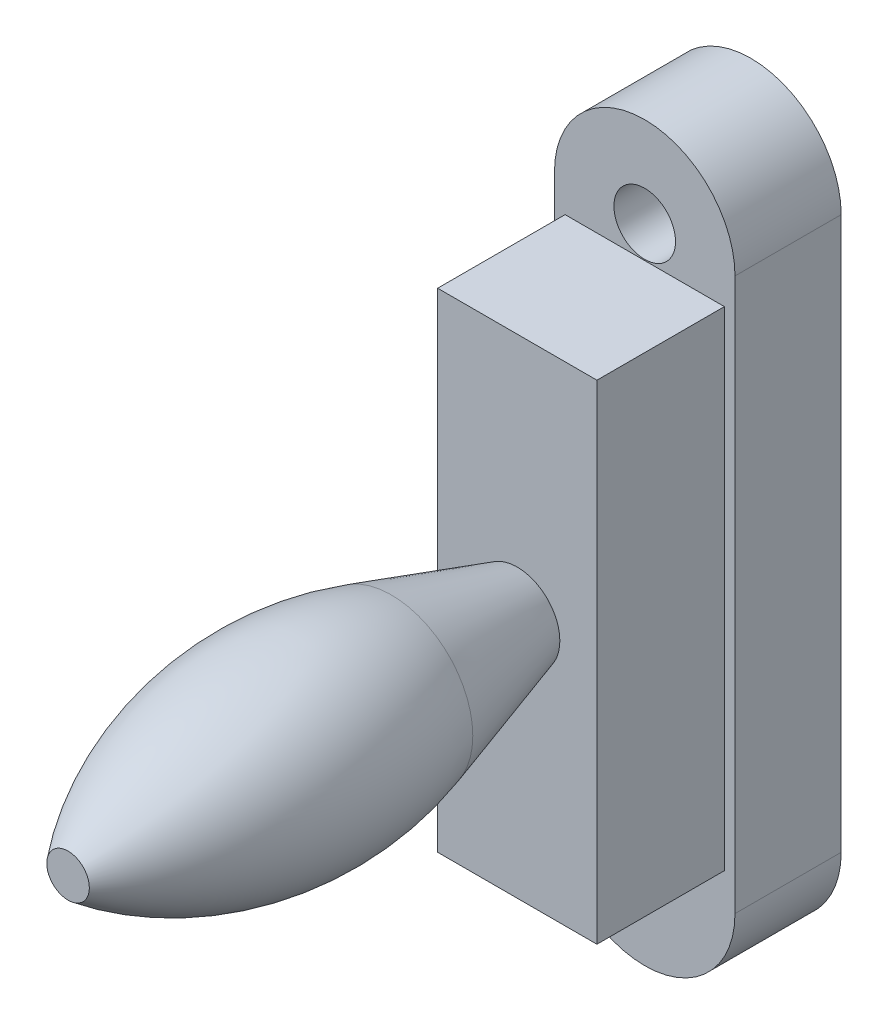
from build123d import *

# Parameters (mm, degrees)
SKETCH1_R           = 1.45
SKETCH1_W           = 4.5
SKETCH1_H           = 20
BOSS_EXTRUDE1_DEPTH = 5
SKETCH2_W           = 7.5
SKETCH2_H           = 23
SKETCH2_W_2         = 4.5
SKETCH2_H_2         = 20
BOSS_EXTRUDE2_DEPTH = 5
SKETCH3_W           = 7.5
SKETCH3_H           = 23
BOSS_EXTRUDE3_DEPTH = 1
CUT_EXTRUDE1_REACH  = 45.372
SKETCH6_R           = 1.25


with BuildPart() as part:
    # Sketch1 → Boss-Extrude1 (new body)
    with BuildSketch(Plane.XY):
        with BuildLine():
            Line((-4.25, 0), (-4.25, 26))
            ThreePointArc((-4.25, 26), (0, 30.25), (4.25, 26))
            Line((4.25, 26), (4.25, 0))
            ThreePointArc((4.25, 0), (0, -4.25), (-4.25, 0))
        make_face()
        with Locations((0, 26)):
            Circle(SKETCH1_R, mode=Mode.SUBTRACT)
        Circle(SKETCH1_R, mode=Mode.SUBTRACT)
        with Locations((0, 13)):
            Rectangle(SKETCH1_W, SKETCH1_H, mode=Mode.SUBTRACT)
    extrude(amount=BOSS_EXTRUDE1_DEPTH)

    # Sketch2 → Boss-Extrude2 (add)
    with BuildSketch(Plane.XY.offset(5)):
        with Locations((0, 13)):
            Rectangle(SKETCH2_W, SKETCH2_H)
        with Locations((0, 13)):
            Rectangle(SKETCH2_W_2, SKETCH2_H_2, mode=Mode.SUBTRACT)
    extrude(amount=BOSS_EXTRUDE2_DEPTH)

    # Sketch3 → Boss-Extrude3 (add)
    with BuildSketch(Plane.XY.offset(10)):
        with Locations((0, 13)):
            Rectangle(SKETCH3_W, SKETCH3_H)
    extrude(amount=BOSS_EXTRUDE3_DEPTH)

    # Sketch5 → Revolve1 (revolve)
    with BuildSketch(Plane(origin=(0, 0, 0), x_dir=(0, 0, -1), z_dir=(1, 0, 0))):
        with BuildLine():
            Line((-11, 13), (-11, 15.003893641))
            Line((-11, 15.003893641), (-16.924450419, 16.829327494))
            ThreePointArc((-16.924450419, 16.829327494), (-24.885658953, 17.288779267), (-32.151240121, 14.001946821))
            Line((-32.151240121, 14.001946821), (-32.151240121, 13))
            Line((-32.151240121, 13), (-11, 13))
        make_face()
    revolve(axis=Axis((0, 13, 32.151240121), (0, 0, -1)))

    # Sketch6 → Cut-Extrude1 (cut, up to next)
    with BuildSketch(Plane.XZ.offset(-1.5), mode=Mode.PRIVATE) as cut_extrude1_sk1:
        with Locations((0, 7.153891294)):
            Circle(SKETCH6_R)
    cut_extrude1_tool1 = extrude(cut_extrude1_sk1.sketch, amount=-CUT_EXTRUDE1_REACH, mode=Mode.PRIVATE) & part.part
    add(cut_extrude1_tool1.solids().sort_by_distance((0, 1.5, 7.153891))[0], mode=Mode.SUBTRACT)


solid = part.part
